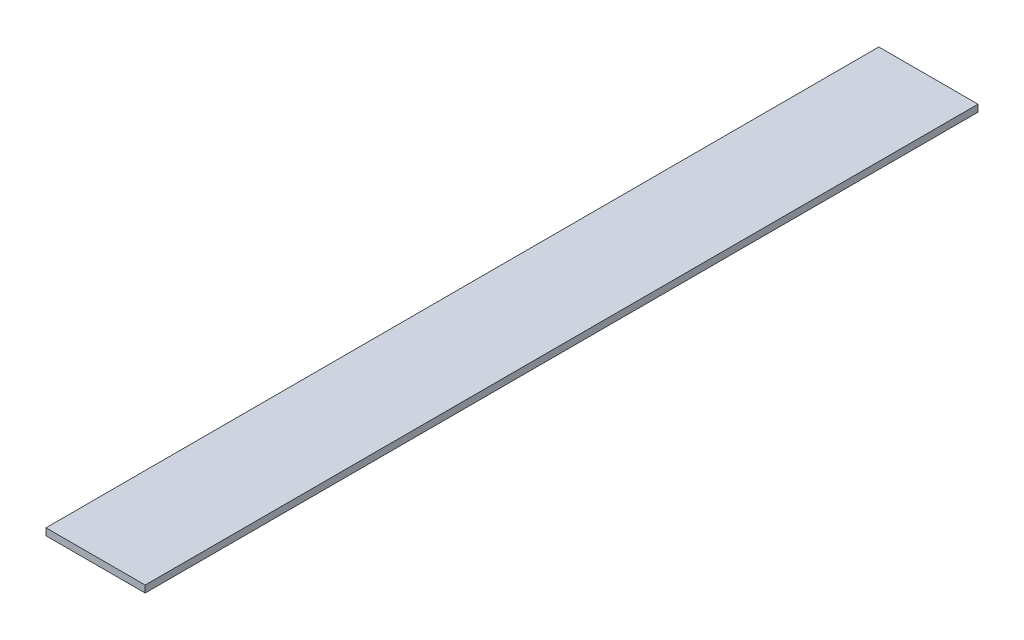
from build123d import *

# Parameters (mm, degrees)
SKETCH1_W           = 100
SKETCH1_H           = 7
BOSS_EXTRUDE1_DEPTH = 840


with BuildPart() as part:
    # Sketch1 → Boss-Extrude1 (new body)
    with BuildSketch(Plane.XY):
        with Locations((18.900342958, 3.5)):
            Rectangle(SKETCH1_W, SKETCH1_H)
    extrude(amount=BOSS_EXTRUDE1_DEPTH)


solid = part.part
